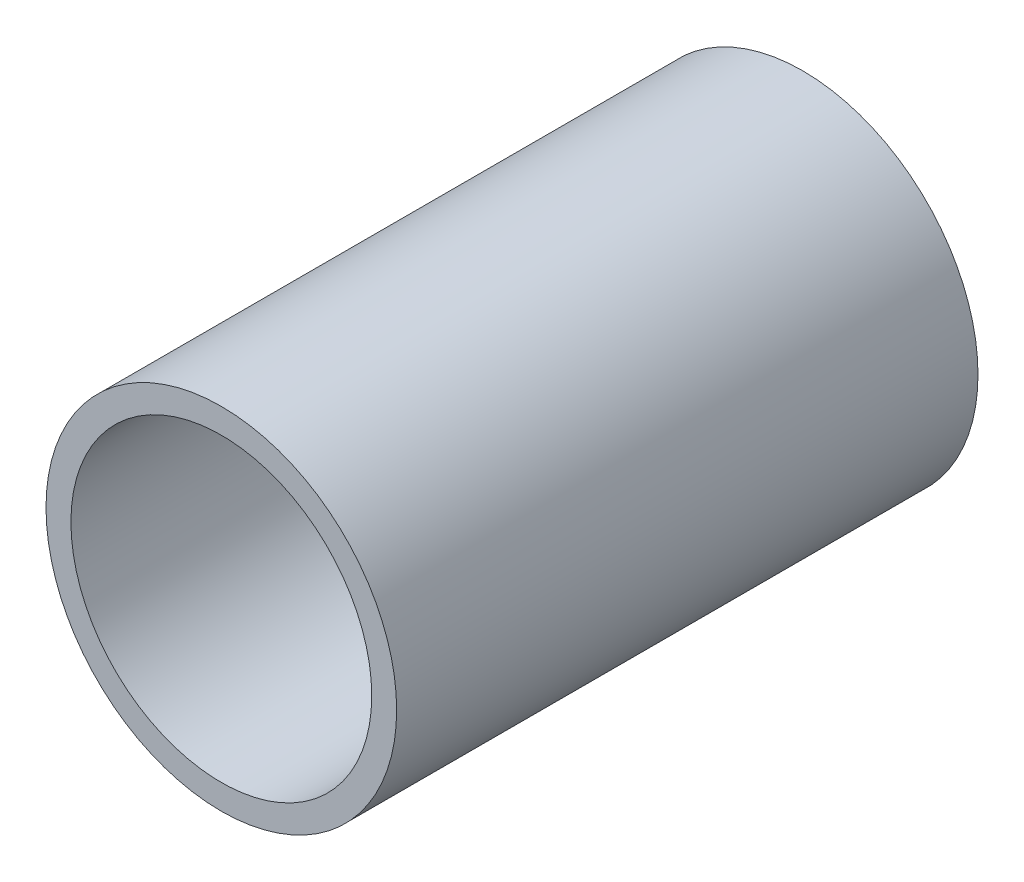
from build123d import *

# Parameters (mm, degrees)
SZKIC1_R                    = 9.5
SZKIC1_R_2                  = 8.15
DODANIE_WYCI_GNI_CIE1_DEPTH = 31.5


with BuildPart() as part:
    # Szkic1 → Dodanie-wyciągnięcie1 (new body)
    with BuildSketch(Plane.XY):
        Circle(SZKIC1_R)
        Circle(SZKIC1_R_2, mode=Mode.SUBTRACT)
    extrude(amount=DODANIE_WYCI_GNI_CIE1_DEPTH)


solid = part.part
